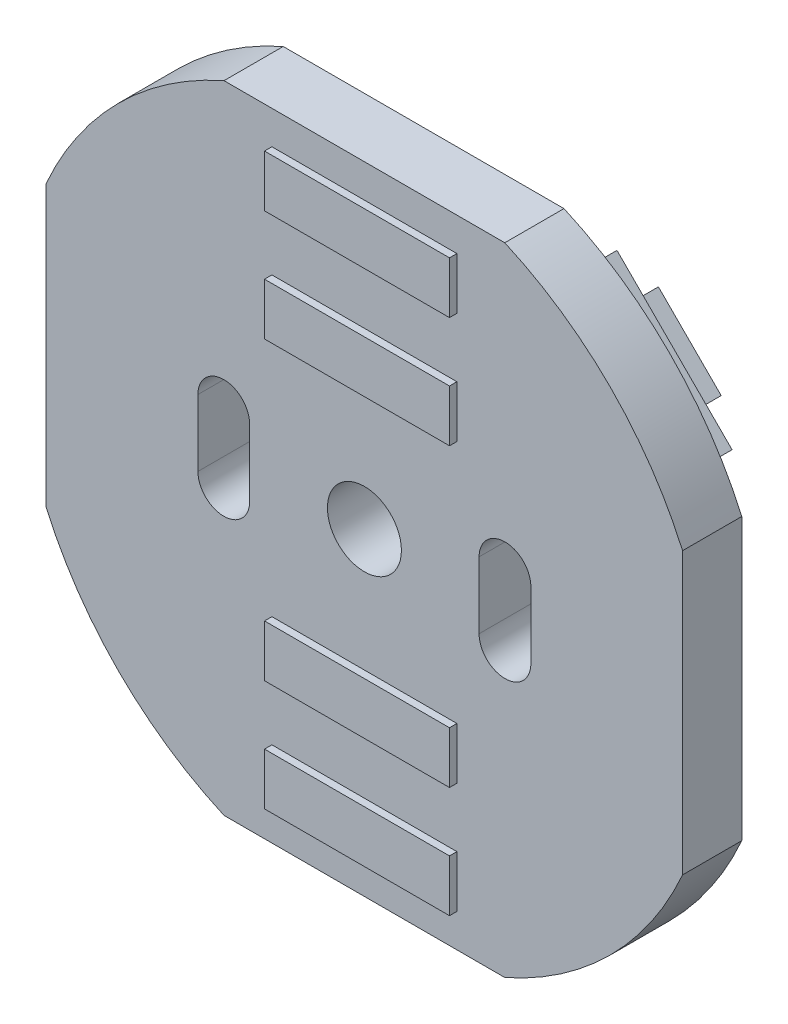
from build123d import *

# Parameters (mm, degrees)
EXTRUDE_5_DEPTH     = 0.8
EXTRUDE_6_DEPTH     = 0.28
EXTRUDE_8_DEPTH     = 0.84
SKETCH_1_9_R        = 0.5
CUT_EXTRUDE_1_DEPTH = 1.8
SKETCH_2_W          = 2.5
SKETCH_2_H          = 0.7
EXTRUDE_9_DEPTH     = 0.1


with BuildPart() as part:
    # Sketch 1 → Extrude 5 (new body)
    with BuildSketch(Plane.XY):
        with BuildLine():
            Line((-1.897366596, -4.3), (1.897366596, -4.3))
            ThreePointArc((1.897366596, -4.3), (3.323401872, -3.323401872), (4.3, -1.897366596))
            Line((4.3, -1.897366596), (4.3, 1.897366596))
            ThreePointArc((4.3, 1.897366596), (3.323401872, 3.323401872), (1.897366596, 4.3))
            Line((1.897366596, 4.3), (-1.897366596, 4.3))
            ThreePointArc((-1.897366596, 4.3), (-3.323401872, 3.323401872), (-4.3, 1.897366596))
            Line((-4.3, 1.897366596), (-4.3, -1.897366596))
            ThreePointArc((-4.3, -1.897366596), (-3.323401872, -3.323401872), (-1.897366596, -4.3))
        make_face()
    extrude(amount=EXTRUDE_5_DEPTH)

    # Sketch 1_6 → Extrude 6 (add)
    with BuildSketch(Plane.XY):
        Polygon((-0.919238816, 2.474873734), (-2.474873734, 0.919238816), (-3.889087297, 2.333452378), (-2.333452378, 3.889087297), align=None)
        Polygon((-1.626345597, 2.474873734), (-2.333452378, 3.181980515), (-3.181980515, 2.333452378), (-2.474873734, 1.626345597), align=None, mode=Mode.SUBTRACT)
        Polygon((2.474873734, 0.919238816), (3.889087297, 2.333452378), (2.333452378, 3.889087297), (0.919238816, 2.474873734), align=None)
        Polygon((2.474873734, 1.626345597), (3.181980515, 2.333452378), (2.333452378, 3.181980515), (1.626345597, 2.474873734), align=None, mode=Mode.SUBTRACT)
        Polygon((0.919238816, -2.474873734), (2.474873734, -0.919238816), (3.889087297, -2.333452378), (2.333452378, -3.889087297), align=None)
        Polygon((1.626345597, -2.474873734), (2.333452378, -3.181980515), (3.181980515, -2.333452378), (2.474873734, -1.626345597), align=None, mode=Mode.SUBTRACT)
        Polygon((-2.474873734, -0.919238816), (-0.919238816, -2.474873734), (-2.333452378, -3.889087297), (-3.889087297, -2.333452378), align=None)
        Polygon((-2.474873734, -1.626345597), (-3.181980515, -2.333452378), (-2.333452378, -3.181980515), (-1.626345597, -2.474873734), align=None, mode=Mode.SUBTRACT)
    extrude(amount=-EXTRUDE_6_DEPTH)

    # Sketch 1_8 → Extrude 8 (add)
    with BuildSketch(Plane.XY):
        Polygon((-1.626345597, 2.474873734), (-2.474873734, 1.626345597), (-3.181980515, 2.333452378), (-2.333452378, 3.181980515), align=None)
        Polygon((2.474873734, 1.626345597), (1.626345597, 2.474873734), (2.333452378, 3.181980515), (3.181980515, 2.333452378), align=None)
        Polygon((1.626345597, -2.474873734), (2.474873734, -1.626345597), (3.181980515, -2.333452378), (2.333452378, -3.181980515), align=None)
        Polygon((-2.474873734, -1.626345597), (-1.626345597, -2.474873734), (-2.333452378, -3.181980515), (-3.181980515, -2.333452378), align=None)
    extrude(amount=-EXTRUDE_8_DEPTH)

    # Sketch 1_9 → Cut-Extrude 1 (cut, through all)
    with BuildSketch(Plane.XY):
        with BuildLine():
            ThreePointArc((-2.25, -0.45), (-1.9, -0.8), (-1.55, -0.45))
            Line((-1.55, -0.45), (-1.55, 0.45))
            ThreePointArc((-1.55, 0.45), (-1.9, 0.8), (-2.25, 0.45))
            Line((-2.25, 0.45), (-2.25, -0.45))
        make_face()
        with BuildLine():
            Line((1.55, 0.45), (1.55, -0.45))
            ThreePointArc((1.55, -0.45), (1.9, -0.8), (2.25, -0.45))
            Line((2.25, -0.45), (2.25, 0.45))
            ThreePointArc((2.25, 0.45), (1.9, 0.8), (1.55, 0.45))
        make_face()
        Circle(SKETCH_1_9_R)
    extrude(amount=CUT_EXTRUDE_1_DEPTH, mode=Mode.SUBTRACT)

    # Sketch 2 → Extrude 9 (add)
    with BuildSketch(Plane.XY.offset(0.8)):
        with Locations((0, 3.5)):
            Rectangle(SKETCH_2_W, SKETCH_2_H)
        with Locations((0, 2)):
            Rectangle(SKETCH_2_W, SKETCH_2_H)
        with Locations((0, -2)):
            Rectangle(SKETCH_2_W, SKETCH_2_H)
        with Locations((0, -3.5)):
            Rectangle(SKETCH_2_W, SKETCH_2_H)
    extrude(amount=EXTRUDE_9_DEPTH)


solid = part.part
